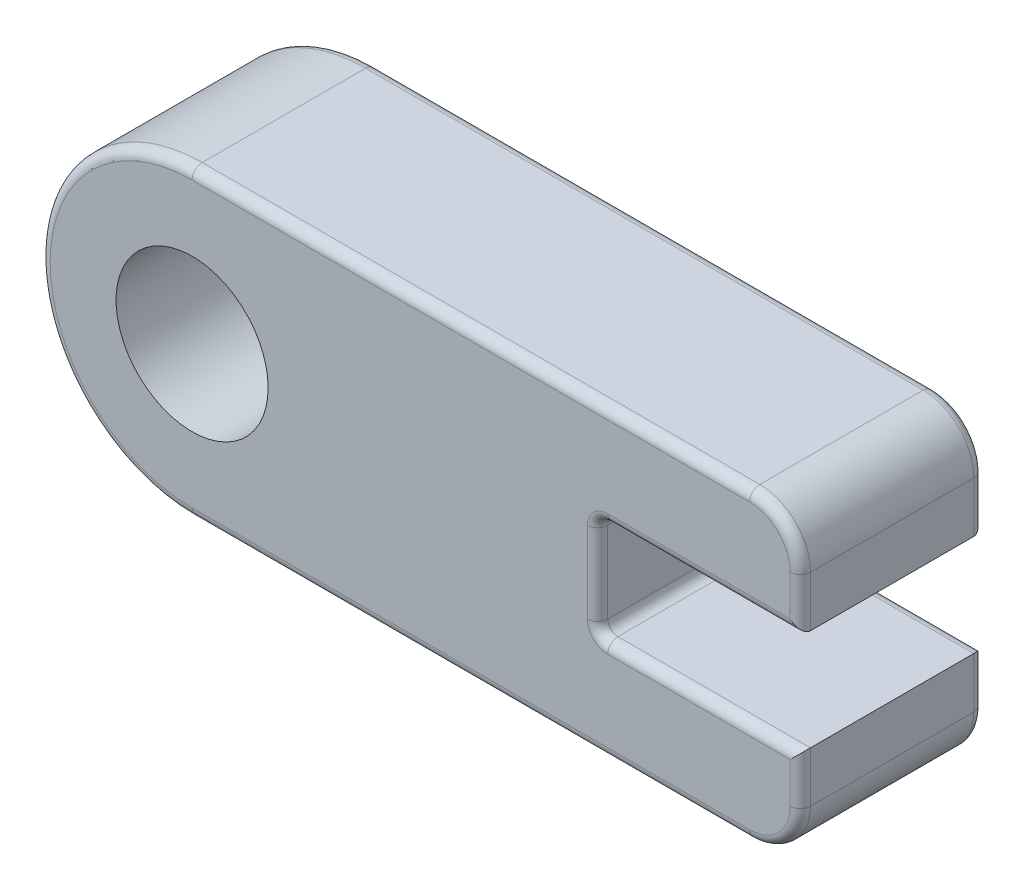
from build123d import *

# Parameters (mm, degrees)
SKETCH1_R           = 19.05
BOSS_EXTRUDE1_DEPTH = 46.001643057
FILLET1_R           = 12.7
FILLET2_R           = 2.54


with BuildPart() as part:
    # Sketch1 → Boss-Extrude1 (new body)
    with BuildSketch(Plane.XY):
        with BuildLine():
            Line((101.6, 12.7), (50.8, 12.7))
            Line((50.8, 12.7), (50.8, -12.7))
            Line((50.8, -12.7), (101.6, -12.7))
            Line((101.6, -12.7), (101.6, -38.1))
            Line((101.6, -38.1), (-50.8, -38.1))
            ThreePointArc((-50.8, -38.1), (-88.9, 0), (-50.8, 38.1))
            Line((-50.8, 38.1), (101.6, 38.1))
            Line((101.6, 38.1), (101.6, 12.7))
        make_face()
        with Locations((-50.8, 0)):
            Circle(SKETCH1_R, mode=Mode.SUBTRACT)
    extrude(amount=BOSS_EXTRUDE1_DEPTH)

    # Fillet1
    fillet1_edges = [part.edges().sort_by_distance(p)[0] for p in [
        (101.6, 38.1, 23.000821528),
        (101.6, -38.1, 23.000821528),
    ]]
    fillet(fillet1_edges, radius=FILLET1_R)

    # Fillet2
    fillet2_edges = [part.edges().sort_by_distance(p)[0] for p in [
        (19.05, -38.1, 0),
        (-88.9, 0, 0),
        (76.2, -12.7, 46.001643057),
        (50.8, 12.7, 23.000821528),
        (50.8, -12.7, 23.000821528),
        (50.8, 0, 46.001643057),
        (76.2, 12.7, 46.001643057),
        (101.6, 19.05, 46.001643057),
        (101.6, -19.05, 0),
        (101.6, -19.05, 46.001643057),
        (19.05, 38.1, 0),
        (97.880256121, 34.380256121, 0),
        (97.880256121, -34.380256121, 0),
        (19.05, 38.1, 46.001643057),
        (97.880256121, 34.380256121, 46.001643057),
        (97.880256121, -34.380256121, 46.001643057),
        (-88.9, 0, 46.001643057),
        (19.05, -38.1, 46.001643057),
        (101.6, 19.05, 0),
        (76.2, 12.7, 0),
        (50.8, 0, 0),
        (76.2, -12.7, 0),
    ]]
    fillet(fillet2_edges, radius=FILLET2_R)


solid = part.part
